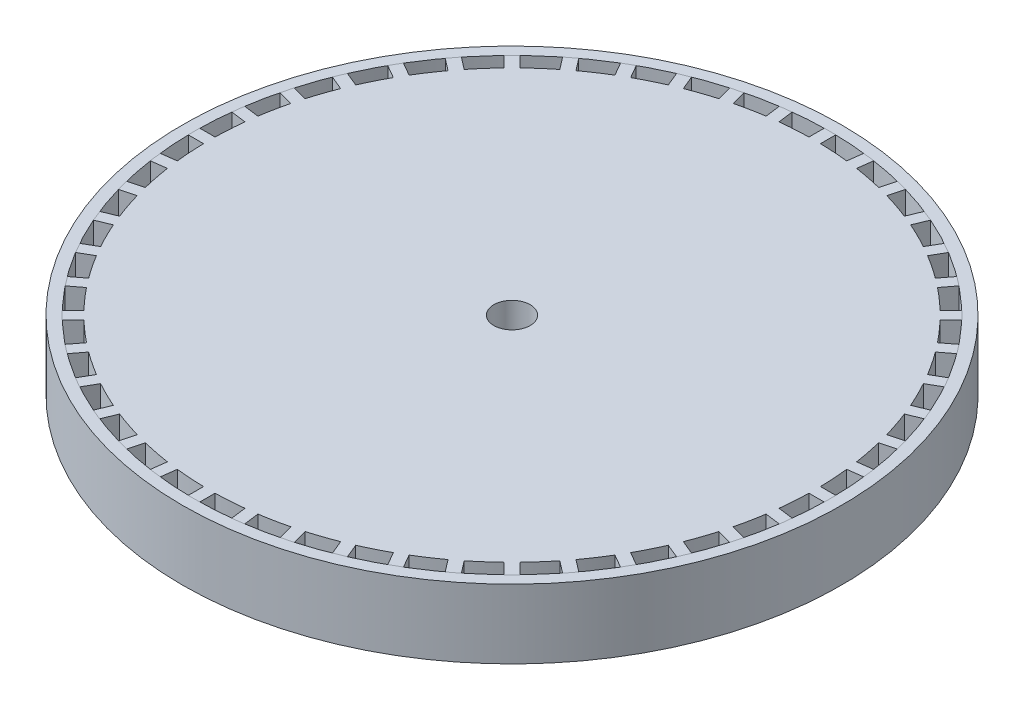
from build123d import *

# Parameters (mm, degrees)
SKETCH1_R             = 83.4644
SKETCH1_R_2           = 5
BOSS_EXTRUDE1_DEPTH   = 9.525
SKETCH1_R_3           = 90.8558
SKETCH1_R_4           = 87.6808
BOSS_EXTRUDE1_2_DEPTH = 9.525
SKETCH2_W             = 4.231498558
SKETCH2_H             = 3.175
BOSS_EXTRUDE2_DEPTH   = 9.525
CIRPATTERN1_COUNT     = 48


with BuildPart() as part:
    # Sketch1 → Boss-Extrude1 (new body, symmetric)
    with BuildSketch(Plane(origin=(0, 0, 0), x_dir=(1, 0, 0), z_dir=(0, 1, 0))):
        Circle(SKETCH1_R)
        Circle(SKETCH1_R_2, mode=Mode.SUBTRACT)
    extrude(amount=BOSS_EXTRUDE1_DEPTH, both=True)

    # Sketch2 → Boss-Extrude2 (add, symmetric)
    with BuildSketch(Plane(origin=(0, 0, 0), x_dir=(1, 0, 0), z_dir=(0, 1, 0))):
        with Locations((85.565050721, 0)):
            Rectangle(SKETCH2_W, SKETCH2_H)
    boss_extrude2 = extrude(amount=BOSS_EXTRUDE2_DEPTH, both=True)

    # CirPattern1: Boss-Extrude2 ×48 about axis
    cirpattern1_axis = Axis((0, 0, 0), (0, 1, 0))
    for i in range(1, CIRPATTERN1_COUNT):
        add(boss_extrude2.rotate(cirpattern1_axis, i * 360 / CIRPATTERN1_COUNT))


with BuildPart() as body_2:
    # Sketch1 → Boss-Extrude1 2 (new body, symmetric)
    with BuildSketch(Plane(origin=(0, 0, 0), x_dir=(1, 0, 0), z_dir=(0, 1, 0))):
        Circle(SKETCH1_R_3)
        Circle(SKETCH1_R_4, mode=Mode.SUBTRACT)
    extrude(amount=BOSS_EXTRUDE1_2_DEPTH, both=True)


solid = Compound([part.part, body_2.part])
